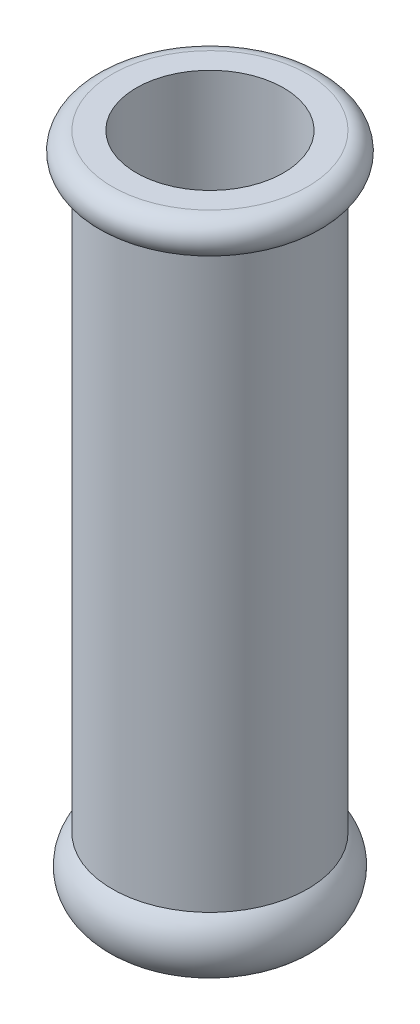
from build123d import *


with BuildPart() as part:
    # Sketch1 → Revolve1 (revolve)
    with BuildSketch(Plane.XY):
        with BuildLine():
            Line((-4.11, 37.6), (-4.11, 0))
            ThreePointArc((-4.11, 0), (-6.05699996, 1.360064568), (-5.45, 3.656177701))
            Line((-5.45, 3.656177701), (-5.45, 35.6))
            ThreePointArc((-5.45, 35.6), (-6.45, 36.6), (-5.45, 37.6))
            Line((-5.45, 37.6), (-4.11, 37.6))
        make_face()
    revolve(axis=Axis((0, 0, 0), (0, 1, 0)))


solid = part.part
